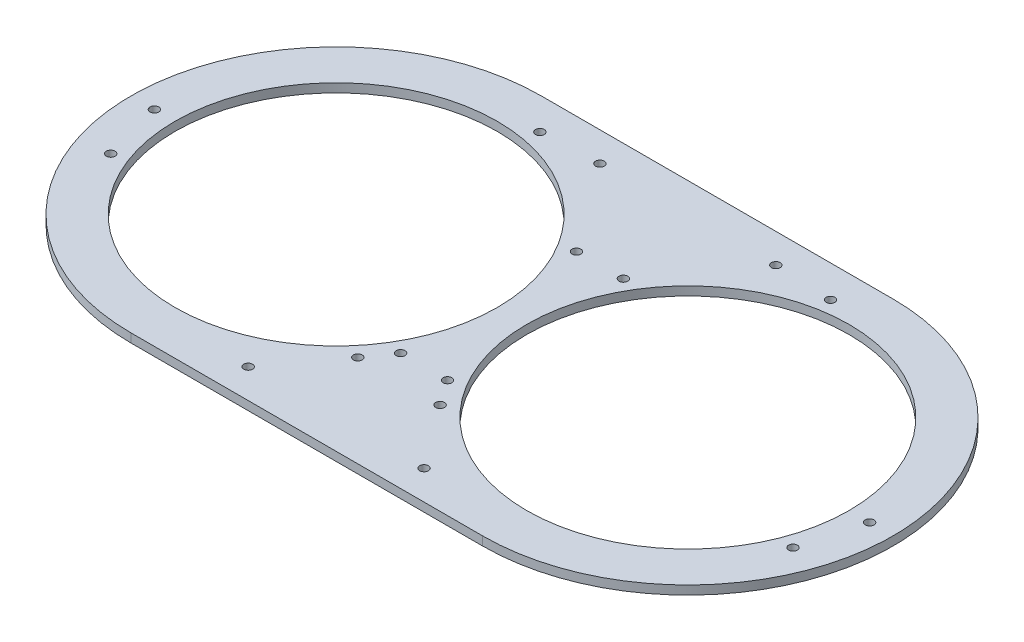
from build123d import *

# Parameters (mm, degrees)
SKETCH_1_R          = 55
SKETCH_1_R_2        = 1.5
EXTRUDE_2_DEPTH     = 3
SKETCH_2_R          = 1.5
CUT_EXTRUDE_1_DEPTH = 10


with BuildPart() as part:
    # 草图1 → 凸台-拉伸2 (new body)
    with BuildSketch(Plane(origin=(0, 0, 0), x_dir=(1, 0, 0), z_dir=(0, 1, 0))):
        with BuildLine():
            Line((-60, 70), (60, 70))
            ThreePointArc((60, 70), (130, 0), (60, -70))
            Line((60, -70), (-60, -70))
            ThreePointArc((-60, -70), (-130, 0), (-60, 70))
        make_face()
        with Locations((-60, 0)):
            Circle(SKETCH_1_R, mode=Mode.SUBTRACT)
        with Locations((60, 0)):
            Circle(SKETCH_1_R, mode=Mode.SUBTRACT)
        with Locations((-122, 0)):
            Circle(SKETCH_1_R_2, mode=Mode.SUBTRACT)
        with Locations((122, 0)):
            Circle(SKETCH_1_R_2, mode=Mode.SUBTRACT)
        with Locations((-30, 60)):
            Circle(SKETCH_1_R_2, mode=Mode.SUBTRACT)
        with Locations((30, 60)):
            Circle(SKETCH_1_R_2, mode=Mode.SUBTRACT)
        with Locations((30, -60)):
            Circle(SKETCH_1_R_2, mode=Mode.SUBTRACT)
        with Locations((-30, -60)):
            Circle(SKETCH_1_R_2, mode=Mode.SUBTRACT)
        with Locations((-49.58110934, 59.088465181)):
            Circle(SKETCH_1_R_2, mode=Mode.SUBTRACT)
        with Locations((-116.381557247, -20.5212086)):
            Circle(SKETCH_1_R_2, mode=Mode.SUBTRACT)
        with Locations((-14.037333413, -38.567256581)):
            Circle(SKETCH_1_R_2, mode=Mode.SUBTRACT)
        with Locations((14.037333413, -38.567256581)):
            Circle(SKETCH_1_R_2, mode=Mode.SUBTRACT)
        with Locations((116.381557247, -20.5212086)):
            Circle(SKETCH_1_R_2, mode=Mode.SUBTRACT)
        with Locations((49.58110934, 59.088465181)):
            Circle(SKETCH_1_R_2, mode=Mode.SUBTRACT)
    extrude(amount=EXTRUDE_2_DEPTH)

    # 草图2 → 切除-拉伸1 (cut)
    with BuildSketch(Plane(origin=(0, 3, 0), x_dir=(1, 0, 0), z_dir=(0, 1, 0))):
        with Locations((-8, -30)):
            Circle(SKETCH_2_R)
        with Locations((8, -30)):
            Circle(SKETCH_2_R)
        with Locations((8, 30)):
            Circle(SKETCH_2_R)
        with Locations((-8, 30)):
            Circle(SKETCH_2_R)
    extrude(amount=-CUT_EXTRUDE_1_DEPTH, mode=Mode.SUBTRACT)


solid = part.part
